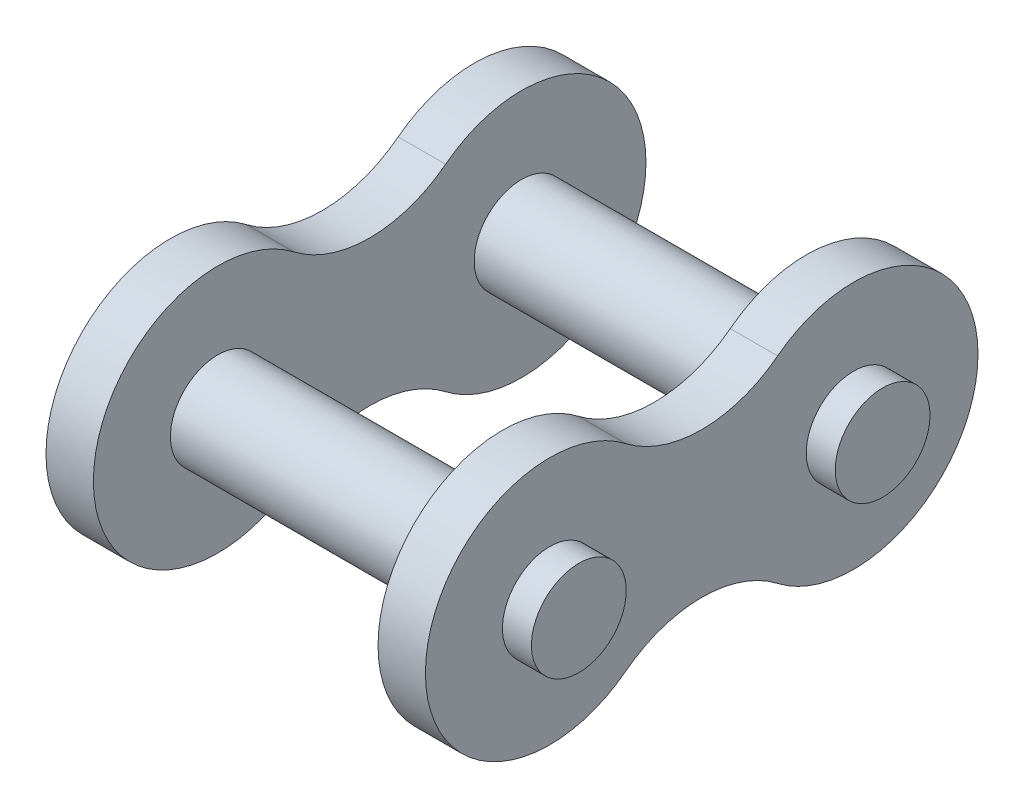
from build123d import *

# Parameters (mm, degrees)
BACK_LINK_SKETCH_R       = 3.9624
BACK_LINK_EXTRUDE_DEPTH  = 3.9624
FRONT_LINK_SKETCH_R      = 3.9624
FRONT_LINK_EXTRUDE_DEPTH = 3.9624
PIN_SKETCH_R             = 3.9624
PIN_EXTRUDE_DEPTH        = 18.288
PIN_EXTRUDE_DEPTH_BACK   = 18.288
PIN_EXTRUDE_2_DEPTH      = 18.288
PIN_EXTRUDE_2_DEPTH_BACK = 18.288


with BuildPart() as part:
    # Back Link Sketch → Back Link Extrude (new body)
    with BuildSketch(Plane(origin=(-11.8999, 0, 0), x_dir=(0, 0, -1), z_dir=(1, 0, 0))):
        with BuildLine():
            ThreePointArc((-6.35, 8.23799379), (-23.1013, 0), (-6.35, -8.23799379))
            ThreePointArc((-6.35, -8.23799379), (0, -6.074687581), (6.35, -8.23799379))
            ThreePointArc((6.35, -8.23799379), (23.1013, 0), (6.35, 8.23799379))
            ThreePointArc((6.35, 8.23799379), (0, 6.074687581), (-6.35, 8.23799379))
        make_face()
        with Locations((-12.7, 0)):
            Circle(BACK_LINK_SKETCH_R, mode=Mode.SUBTRACT)
        with Locations((12.7, 0)):
            Circle(BACK_LINK_SKETCH_R, mode=Mode.SUBTRACT)
    extrude(amount=-BACK_LINK_EXTRUDE_DEPTH)


with BuildPart() as body_2:
    # Front Link Sketch → Front Link Extrude (new body)
    with BuildSketch(Plane(origin=(11.8999, 0, 0), x_dir=(0, 0, -1), z_dir=(1, 0, 0))):
        with BuildLine():
            ThreePointArc((-6.35, 8.23799379), (0, 6.074687581), (6.35, 8.23799379))
            ThreePointArc((6.35, 8.23799379), (23.1013, 0), (6.35, -8.23799379))
            ThreePointArc((6.35, -8.23799379), (0, -6.074687581), (-6.35, -8.23799379))
            ThreePointArc((-6.35, -8.23799379), (-23.1013, 0), (-6.35, 8.23799379))
        make_face()
        with Locations((-12.7, 0)):
            Circle(FRONT_LINK_SKETCH_R, mode=Mode.SUBTRACT)
        with Locations((12.7, 0)):
            Circle(FRONT_LINK_SKETCH_R, mode=Mode.SUBTRACT)
    extrude(amount=FRONT_LINK_EXTRUDE_DEPTH)


with BuildPart() as body_3:
    # Pin Sketch → Pin Extrude (new body, two sides)
    with BuildSketch(Plane(origin=(0, 0, 0), x_dir=(0, 0, -1), z_dir=(1, 0, 0))) as pin_extrude_sk:
        with Locations((12.7, 0)):
            Circle(PIN_SKETCH_R)
    extrude(amount=PIN_EXTRUDE_DEPTH)
    extrude(pin_extrude_sk.sketch, amount=-PIN_EXTRUDE_DEPTH_BACK)


with BuildPart() as body_4:
    # Pin Sketch → Pin Extrude 2 (new body, two sides)
    with BuildSketch(Plane(origin=(0, 0, 0), x_dir=(0, 0, -1), z_dir=(1, 0, 0))) as pin_extrude_2_sk:
        with Locations((-12.7, 0)):
            Circle(PIN_SKETCH_R)
    extrude(amount=PIN_EXTRUDE_2_DEPTH)
    extrude(pin_extrude_2_sk.sketch, amount=-PIN_EXTRUDE_2_DEPTH_BACK)


solid = Compound([part.part, body_2.part, body_3.part, body_4.part])
